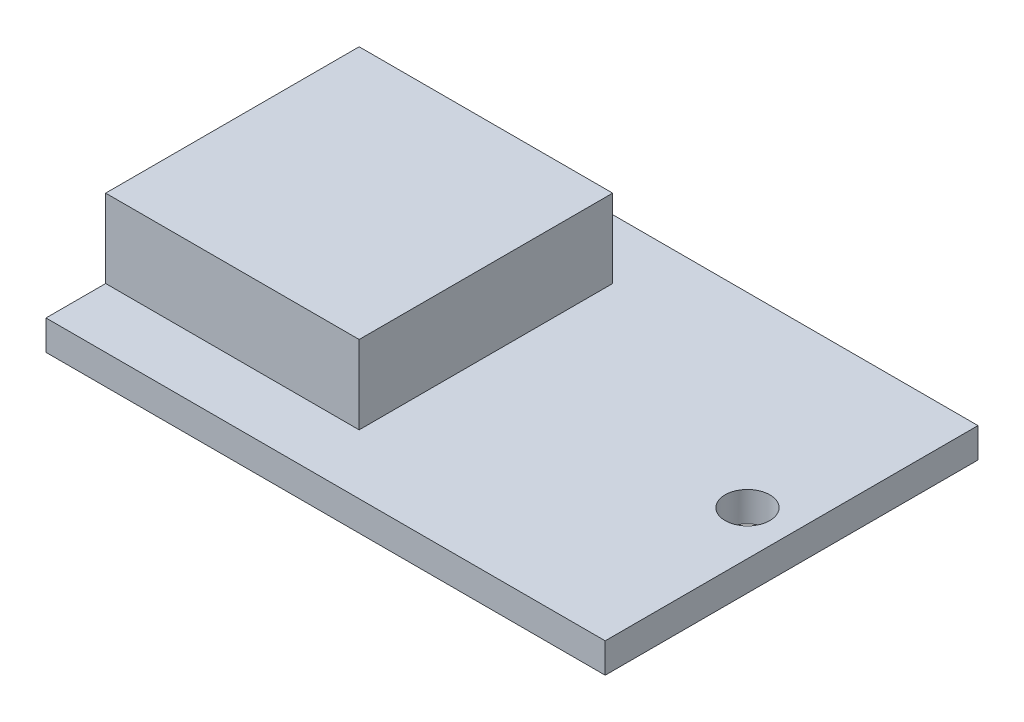
from build123d import *

# Parameters (mm, degrees)
BOSS_EXTRUDE2_DEPTH = 4
BOSS_EXTRUDE4_DEPTH = 10.5
SKETCH9_R           = 3
CUT_EXTRUDE1_DEPTH  = 10


with BuildPart() as part:
    # Sketch1 → Boss-Extrude2 (new body)
    with BuildSketch(Plane(origin=(0, 0, 0), x_dir=(1, 0, 0), z_dir=(0, 1, 0))):
        Polygon((0, 0), (0, 25), (75, 25), (75, -25), (0, -25), align=None)
    extrude(amount=BOSS_EXTRUDE2_DEPTH)

    # Sketch7 → Boss-Extrude4 (add)
    with BuildSketch(Plane(origin=(0, 4, 0), x_dir=(1, 0, 0), z_dir=(0, 1, 0))):
        Polygon((0, 0), (0, 17), (34, 17), (34, -17), (0, -17), align=None)
    extrude(amount=BOSS_EXTRUDE4_DEPTH)

    # Sketch9 → Cut-Extrude1 (cut)
    with BuildSketch(Plane(origin=(0, 4, 0), x_dir=(1, 0, 0), z_dir=(0, 1, 0))):
        with Locations((69.078986276, 0)):
            Circle(SKETCH9_R)
    extrude(amount=-CUT_EXTRUDE1_DEPTH, mode=Mode.SUBTRACT)


solid = part.part
